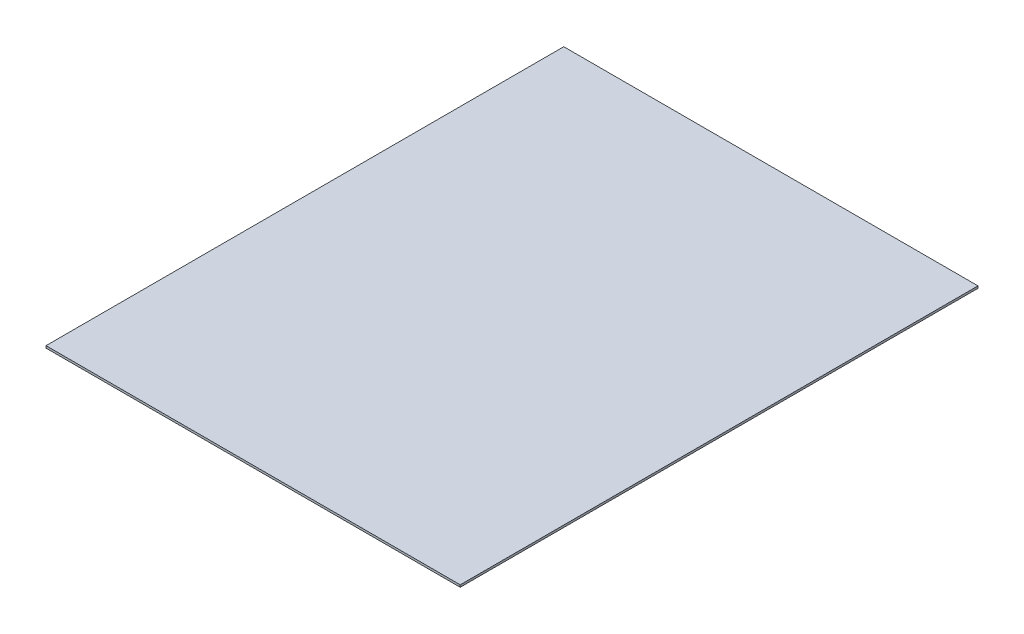
from build123d import *

# Parameters (mm, degrees)
SKETCH1_W           = 1219.2
SKETCH1_H           = 1524
BOSS_EXTRUDE1_DEPTH = 6.35


with BuildPart() as part:
    # Sketch1 → Boss-Extrude1 (new body)
    with BuildSketch(Plane(origin=(0, 0, 0), x_dir=(1, 0, 0), z_dir=(0, 1, 0))):
        Rectangle(SKETCH1_W, SKETCH1_H)
    extrude(amount=BOSS_EXTRUDE1_DEPTH)


solid = part.part
